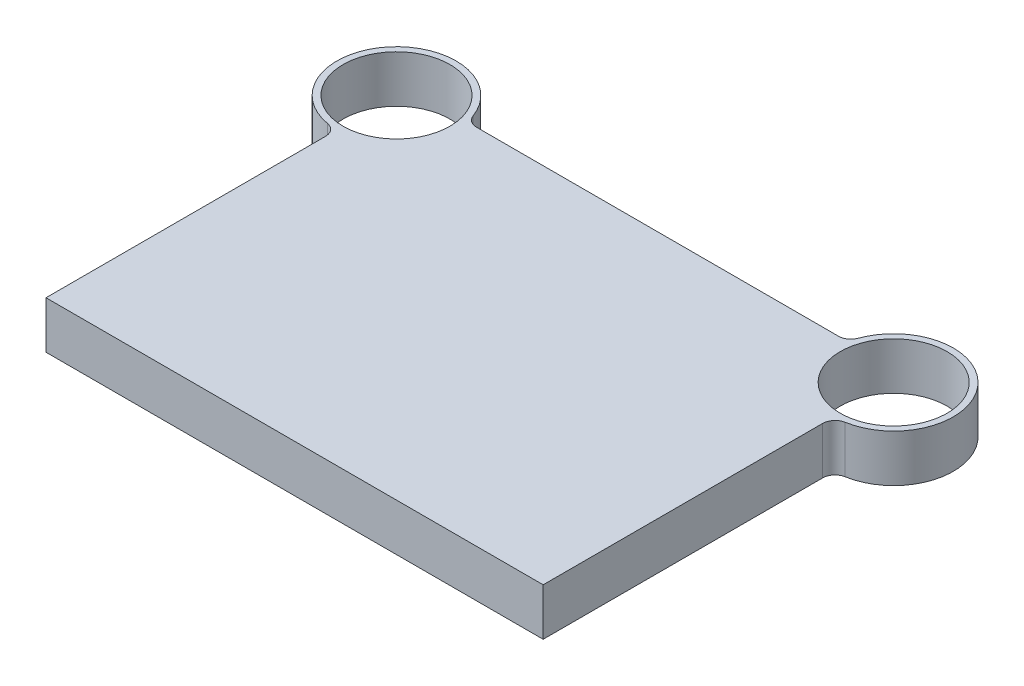
from build123d import *

# Parameters (mm, degrees)
SKETCH1_R           = 43
BOSS_EXTRUDE1_DEPTH = 38
FILLET1_R           = 10


with BuildPart() as part:
    # Sketch1 → Boss-Extrude1 (new body)
    with BuildSketch(Plane(origin=(0, 0, 0), x_dir=(1, 0, 0), z_dir=(0, 1, 0))):
        with BuildLine():
            Line((200, 0), (-200, 0))
            Line((-200, 0), (-200, 234))
            ThreePointArc((-200, 234), (-237.309516212, 312.199337741), (-153.053221623, 292))
            Line((-153.053221623, 292), (153.053221623, 292))
            ThreePointArc((153.053221623, 292), (237.309516212, 312.199337741), (200, 234))
            Line((200, 234), (200, 0))
        make_face()
        with Locations((-200, 282)):
            Circle(SKETCH1_R, mode=Mode.SUBTRACT)
        with Locations((200, 282)):
            Circle(SKETCH1_R, mode=Mode.SUBTRACT)
    extrude(amount=BOSS_EXTRUDE1_DEPTH)

    # Fillet1
    fillet1_edges = [part.edges().sort_by_distance(p)[0] for p in [
        (-200, 19, -234),
        (-153.053221623, 19, -292),
        (153.053221623, 19, -292),
        (200, 19, -234),
    ]]
    fillet(fillet1_edges, radius=FILLET1_R)


solid = part.part
